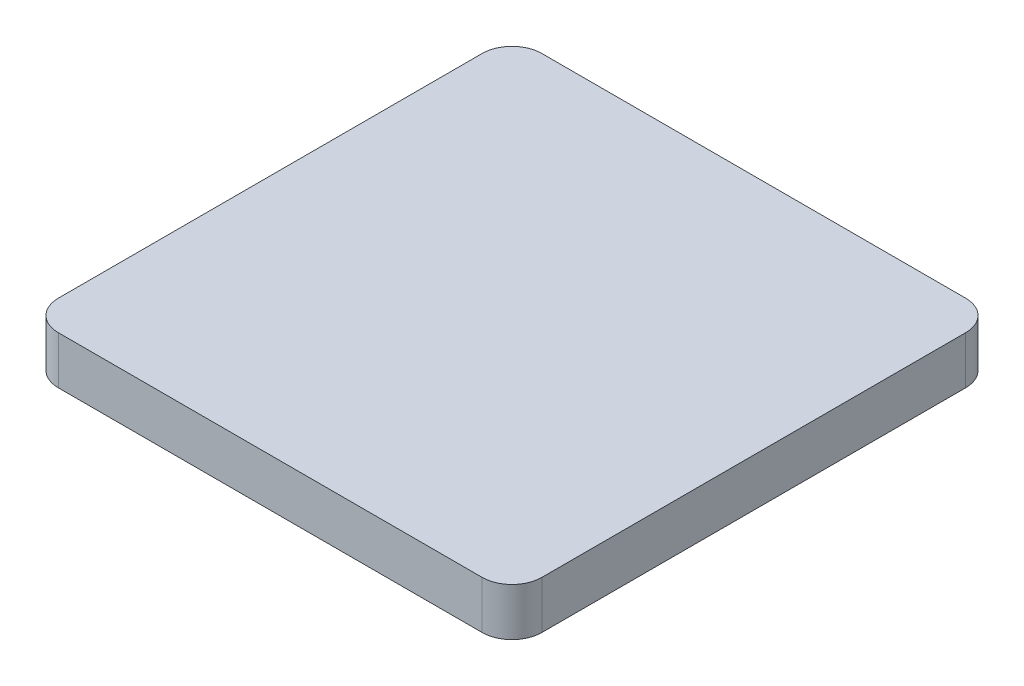
from build123d import *

# Parameters (mm, degrees)
SKETCH2_W           = 81
SKETCH2_H           = 81
BOSS_EXTRUDE1_DEPTH = 4
CUT_EXTRUDE1_DEPTH  = 4
FILLET1_R           = 5


with BuildPart() as part:
    # Sketch2 → Boss-Extrude1 (new body, symmetric)
    with BuildSketch(Plane(origin=(0, 0, 0), x_dir=(1, 0, 0), z_dir=(0, 1, 0))):
        Rectangle(SKETCH2_W, SKETCH2_H)
    extrude(amount=BOSS_EXTRUDE1_DEPTH, both=True)

    # Sketch1 → Cut-Extrude1 (cut)
    with BuildSketch(Plane(origin=(0, 0, 0), x_dir=(1, 0, 0), z_dir=(0, 1, 0))):
        with BuildLine():
            Line((22.5, 36.5), (-32.5, 36.5))
            ThreePointArc((-32.5, 36.5), (-35.328427125, 35.328427125), (-36.5, 32.5))
            Line((-36.5, 32.5), (-36.5, -32.5))
            ThreePointArc((-36.5, -32.5), (-35.328427125, -35.328427125), (-32.5, -36.5))
            Line((-32.5, -36.5), (32.5, -36.5))
            ThreePointArc((32.5, -36.5), (35.328427125, -35.328427125), (36.5, -32.5))
            Line((36.5, -32.5), (36.5, 32.5))
            ThreePointArc((36.5, 32.5), (35.328427125, 35.328427125), (32.5, 36.5))
            ThreePointArc((32.5, 36.5), (27.5, 31.5), (22.5, 36.5))
        make_face()
    extrude(amount=-CUT_EXTRUDE1_DEPTH, mode=Mode.SUBTRACT)

    # Fillet1
    fillet1_edges = [part.edges().sort_by_distance(p)[0] for p in [
        (-40.5, 0, 40.5),
        (-40.5, 0, -40.5),
        (40.5, 0, -40.5),
        (40.5, 0, 40.5),
    ]]
    fillet(fillet1_edges, radius=FILLET1_R)


solid = part.part
